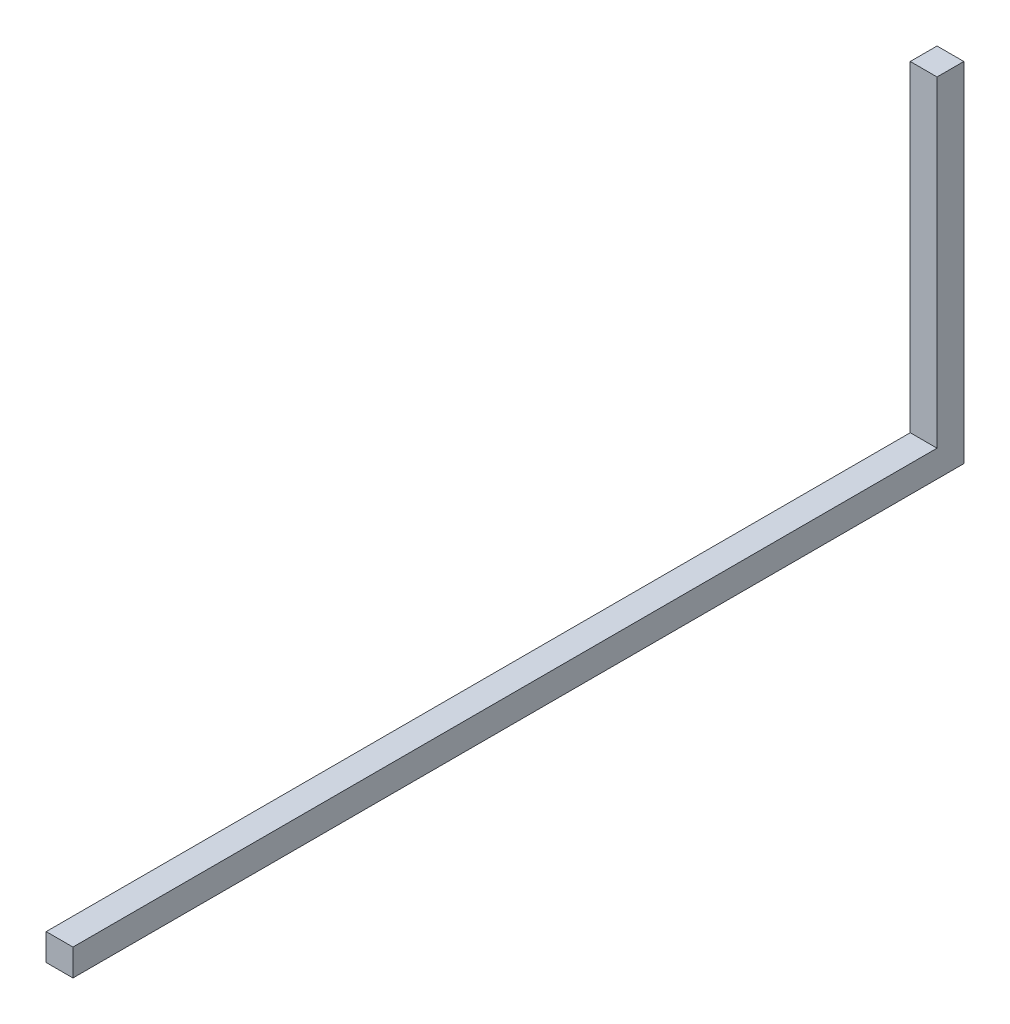
from build123d import *

# Parameters (mm, degrees)
SKETCH_4_W = 0.4
SKETCH_4_H = 0.4


with BuildPart() as part:
    # По траектории1: sweep along a curve in space
    with BuildLine() as sweep_1_path:
        Line((0, 0, 0), (0, 0, -13.1))
        Line((0, 0, -13.1), (0, 5, -13.1))
    # Эскиз4 → По траектории1 (sweep)
    with BuildSketch(Plane.XY):
        Rectangle(SKETCH_4_W, SKETCH_4_H)
    sweep(path=sweep_1_path.line, transition=Transition.RIGHT)


solid = part.part
